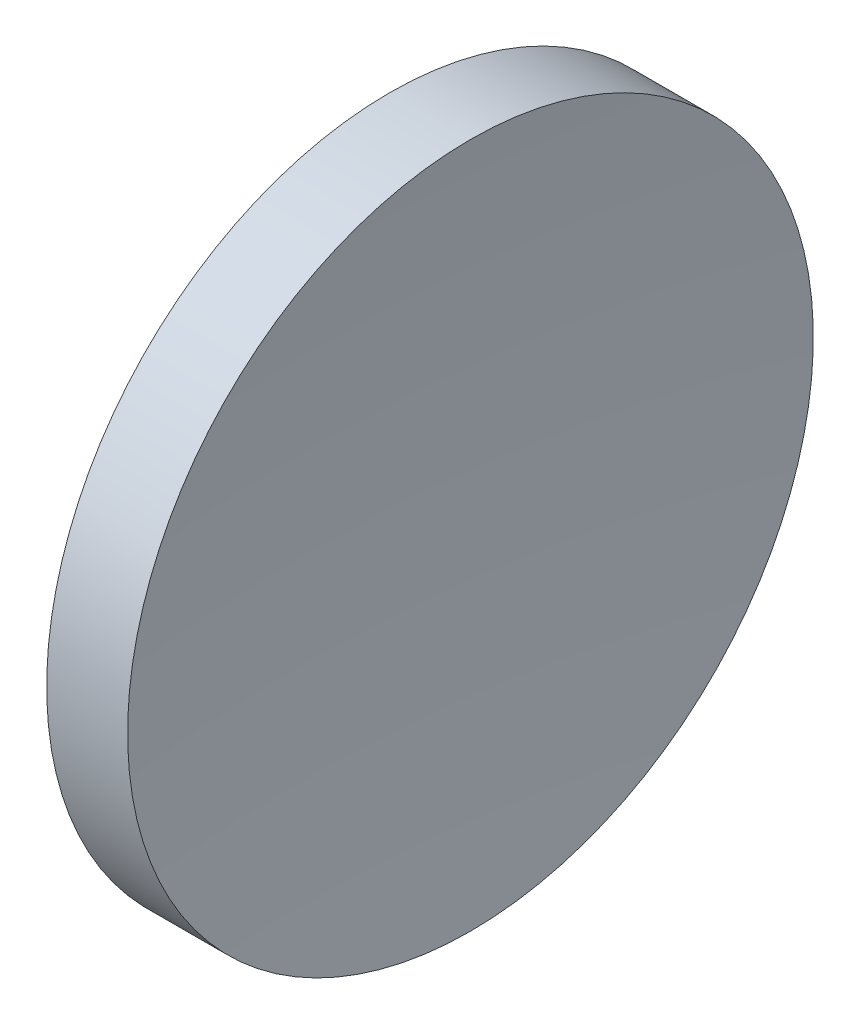
from build123d import *


with BuildPart() as part:
    # 草图1 → 旋转1 (revolve)
    with BuildSketch(Plane.XY, mode=Mode.PRIVATE) as revolve_1_sk:
        with BuildLine():
            Line((44.854422626, 26.062252183), (44.854422626, 34.062252183))
            Line((44.854422626, 34.062252183), (46.742641376, 34.062252183))
            ThreePointArc((46.742641376, 34.062252183), (46.451532194, 30.066959326), (46.354422626, 26.062252183))
            Line((46.354422626, 26.062252183), (44.854422626, 26.062252183))
        make_face()
    revolve(revolve_1_sk.sketch.rotate(Axis((43.011950236, 26.062252183, 0), (1, 0, 0)), 180), axis=Axis((43.011950236, 26.062252183, 0), (1, 0, 0)))  # turned: the seam where the file's is


solid = part.part
